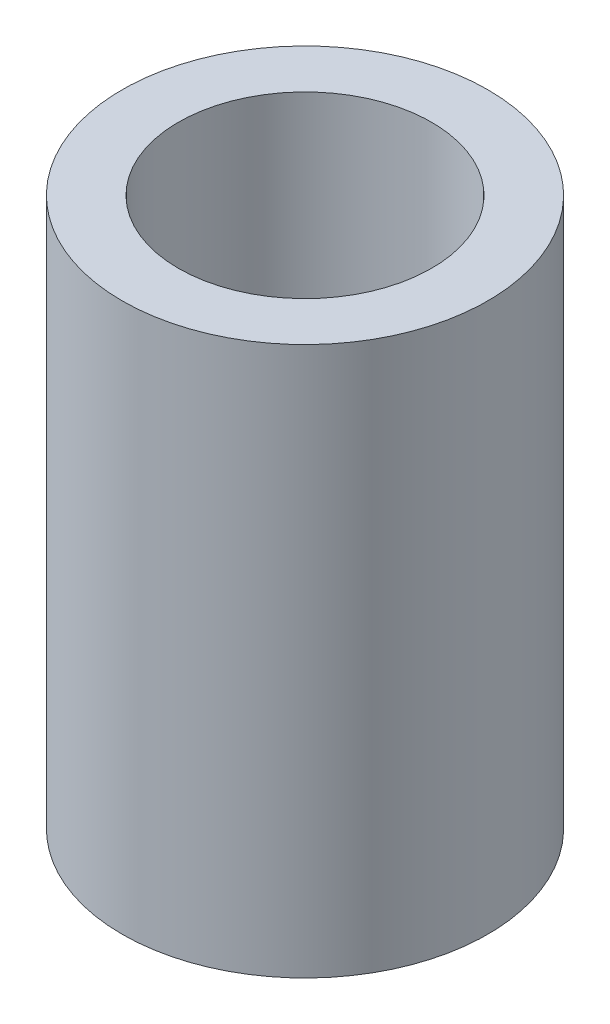
from build123d import *

# Parameters (mm, degrees)
CROQUIS1_R              = 6.5
CROQUIS1_R_2            = 4.5
SALIENTE_EXTRUIR1_DEPTH = 19.5


with BuildPart() as part:
    # Croquis1 → Saliente-Extruir1 (new body)
    with BuildSketch(Plane(origin=(0, 0, 0), x_dir=(1, 0, 0), z_dir=(0, 1, 0))):
        Circle(CROQUIS1_R)
        Circle(CROQUIS1_R_2, mode=Mode.SUBTRACT)
    extrude(amount=SALIENTE_EXTRUIR1_DEPTH)


solid = part.part
